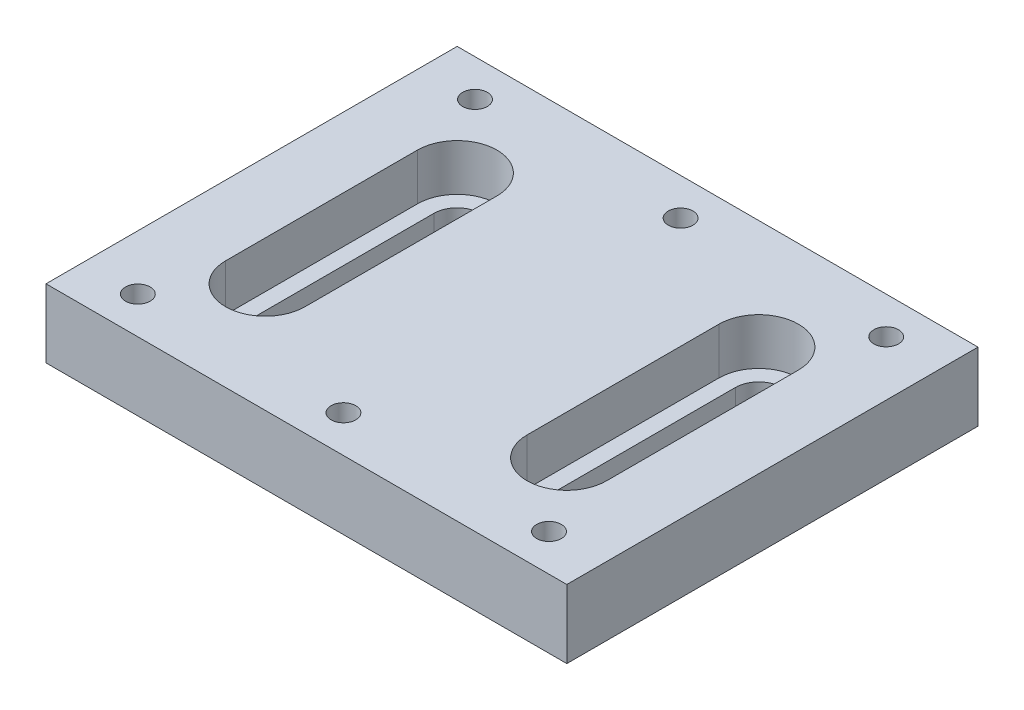
from build123d import *

# Parameters (mm, degrees)
SKETCH1_W           = 48.26
SKETCH1_H           = 38.1
BOSS_EXTRUDE1_DEPTH = 6.35
SKETCH2_R           = 3.683
CUT_EXTRUDE1_DEPTH  = 4.318
SKETCH3_R           = 2.159
CUT_EXTRUDE2_DEPTH  = 4.318
SKETCH4_R           = 1.143
CUT_EXTRUDE3_DEPTH  = 9.398
LPATTERN1_COUNT     = 3
LPATTERN1_PITCH     = 19.05
CUT_EXTRUDE7_DEPTH  = 4.318
CUT_EXTRUDE8_DEPTH  = 10.16


with BuildPart() as part:
    # Sketch1 → Boss-Extrude1 (new body)
    with BuildSketch(Plane(origin=(0, 0, 0), x_dir=(1, 0, 0), z_dir=(0, 1, 0))):
        Rectangle(SKETCH1_W, SKETCH1_H)
    extrude(amount=-BOSS_EXTRUDE1_DEPTH)

    # Sketch2 → Cut-Extrude1 (cut)
    with BuildSketch(Plane(origin=(0, 0, 0), x_dir=(1, 0, 0), z_dir=(0, 1, 0))):
        with Locations((-13.97, 0)):
            Circle(SKETCH2_R)
    cut_extrude1 = extrude(amount=-CUT_EXTRUDE1_DEPTH, mode=Mode.SUBTRACT)

    # Sketch3 → Cut-Extrude2 (cut)
    with BuildSketch(Plane(origin=(0, -4.318, 0), x_dir=(1, 0, 0), z_dir=(0, 1, 0))):
        with Locations((-13.97, 0)):
            Circle(SKETCH3_R)
    cut_extrude2 = extrude(amount=-CUT_EXTRUDE2_DEPTH, mode=Mode.SUBTRACT)

    # Sketch4 → Cut-Extrude3 (cut)
    with BuildSketch(Plane(origin=(0, 0, 0), x_dir=(1, 0, 0), z_dir=(0, 1, 0))):
        with Locations((-19.05, 15.621)):
            Circle(SKETCH4_R)
        with Locations((-19.05, -15.621)):
            Circle(SKETCH4_R)
    cut_extrude3 = extrude(amount=-CUT_EXTRUDE3_DEPTH, mode=Mode.SUBTRACT)

    # LPattern1: Cut-Extrude3 ×3
    with Locations(*[(i * LPATTERN1_PITCH, 0, 0) for i in range(1, LPATTERN1_COUNT)]):
        add(cut_extrude3, mode=Mode.SUBTRACT)

    # Mirror1: Cut-Extrude1, Cut-Extrude2 across plane
    add(cut_extrude1.mirror(Plane(origin=(0, 0, 0), x_dir=(0, 0, 1), z_dir=(1, 0, 0))), mode=Mode.SUBTRACT)
    add(cut_extrude2.mirror(Plane(origin=(0, 0, 0), x_dir=(0, 0, 1), z_dir=(1, 0, 0))), mode=Mode.SUBTRACT)

    # Sketch6 → Cut-Extrude7 (cut)
    with BuildSketch(Plane(origin=(0, 0, 0), x_dir=(1, 0, 0), z_dir=(0, 1, 0))):
        with BuildLine():
            Line((-17.653, -8.89), (-17.653, 8.89))
            ThreePointArc((-17.653, 8.89), (-13.97, 12.573), (-10.287, 8.89))
            Line((-10.287, 8.89), (-10.287, -8.89))
            ThreePointArc((-10.287, -8.89), (-13.97, -12.573), (-17.653, -8.89))
        make_face()
    cut_extrude7 = extrude(amount=-CUT_EXTRUDE7_DEPTH, mode=Mode.SUBTRACT)

    # Sketch7 → Cut-Extrude8 (cut)
    with BuildSketch(Plane(origin=(0, -4.318, 0), x_dir=(1, 0, 0), z_dir=(0, 1, 0))):
        with BuildLine():
            Line((-16.129, -8.89), (-16.129, 8.89))
            ThreePointArc((-16.129, 8.89), (-13.97, 11.049), (-11.811, 8.89))
            Line((-11.811, 8.89), (-11.811, -8.89))
            ThreePointArc((-11.811, -8.89), (-13.97, -11.049), (-16.129, -8.89))
        make_face()
    cut_extrude8 = extrude(amount=-CUT_EXTRUDE8_DEPTH, mode=Mode.SUBTRACT)

    # Mirror2: Cut-Extrude7, Cut-Extrude8 across plane
    add(cut_extrude7.mirror(Plane(origin=(0, 0, 0), x_dir=(0, 0, 1), z_dir=(1, 0, 0))), mode=Mode.SUBTRACT)
    add(cut_extrude8.mirror(Plane(origin=(0, 0, 0), x_dir=(0, 0, 1), z_dir=(1, 0, 0))), mode=Mode.SUBTRACT)


solid = part.part
